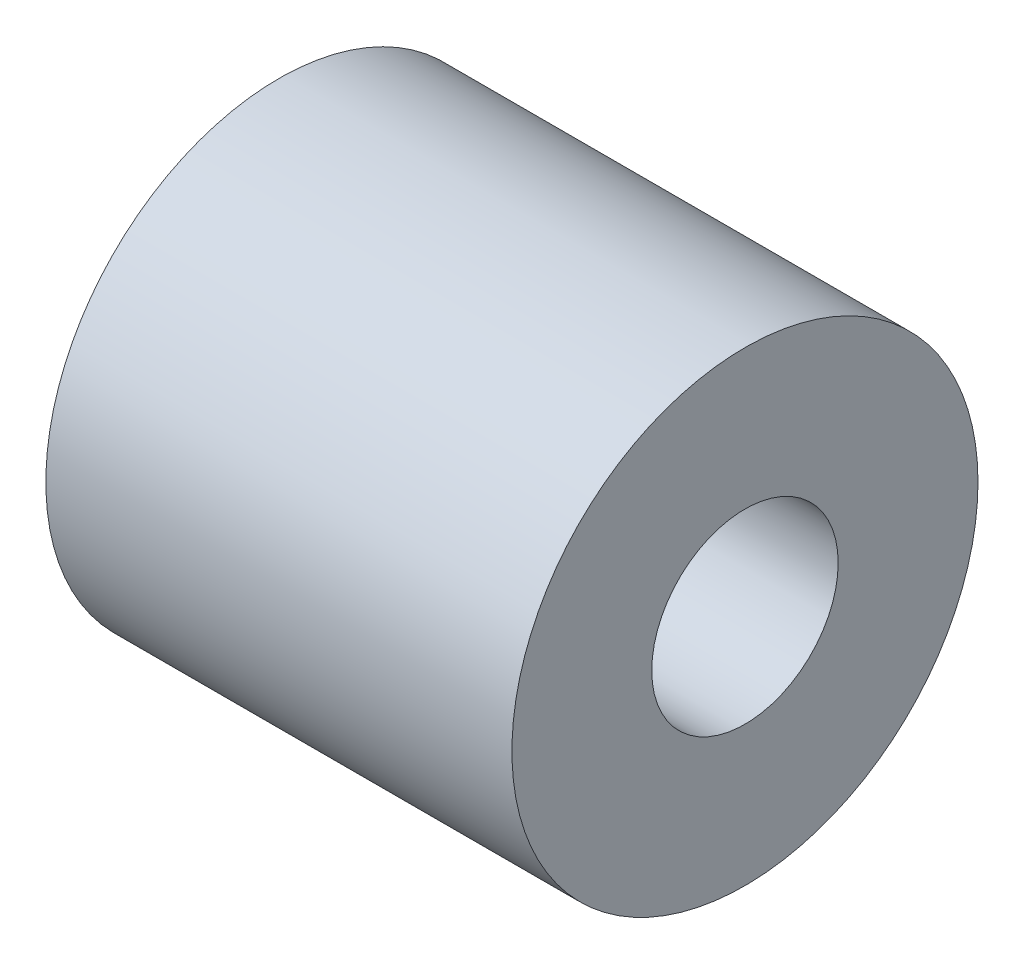
from build123d import *

# Parameters (mm, degrees)
SKETCH1_R           = 2.5
SKETCH1_R_2         = 1
BOSS_EXTRUDE1_DEPTH = 5


with BuildPart() as part:
    # Sketch1 → Boss-Extrude1 (new body)
    with BuildSketch(Plane(origin=(0, 0, 0), x_dir=(0, 0, -1), z_dir=(1, 0, 0))):
        Circle(SKETCH1_R)
        Circle(SKETCH1_R_2, mode=Mode.SUBTRACT)
    extrude(amount=BOSS_EXTRUDE1_DEPTH)


solid = part.part
